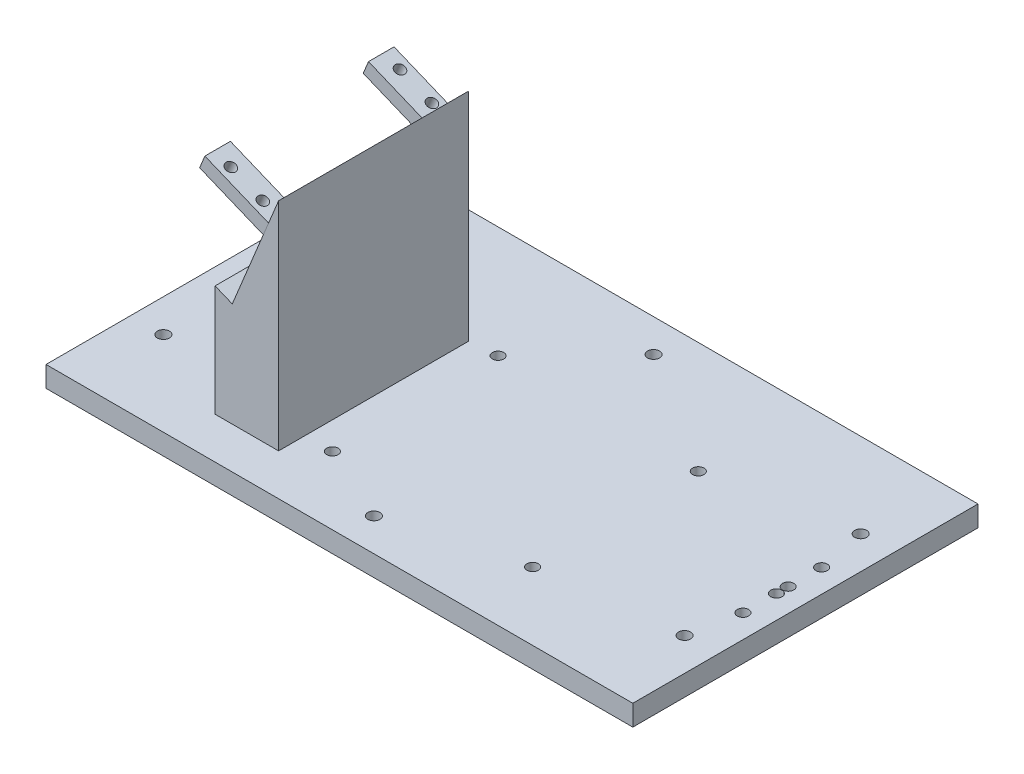
from build123d import *

# Parameters (mm, degrees)
SKETCH1_W                = 170
SKETCH1_H                = 100
BOSS_EXTRUDE1_DEPTH      = 6
BOSS_EXTRUDE2_DEPTH      = 38
BOSS_EXTRUDE2_DEPTH_BACK = 17
SKETCH3_W                = 7.4
SKETCH3_H                = 4
BOSS_EXTRUDE3_DEPTH      = 20
SKETCH5_R                = 1.45
CUT_EXTRUDE1_DEPTH       = 10
SKETCH6_R                = 1.75
CUT_EXTRUDE2_DEPTH       = 20
SKETCH7_R                = 1.65
CUT_EXTRUDE3_DEPTH       = 10
SKETCH9_R                = 1.65
CUT_EXTRUDE6_DEPTH       = 6


with BuildPart() as part:
    # Sketch1 → Boss-Extrude1 (new body)
    with BuildSketch(Plane(origin=(0, 0, 0), x_dir=(1, 0, 0), z_dir=(0, 1, 0))):
        Rectangle(SKETCH1_W, SKETCH1_H)
    extrude(amount=BOSS_EXTRUDE1_DEPTH)

    # Sketch2 → Boss-Extrude2 (add, two sides)
    with BuildSketch(Plane.XY) as boss_extrude2_sk:
        Polygon((-29.617343581, 68.757920077), (-29.617343581, 6), (-48.010328849, 6), (-48.010328849, 38.210127837), (-43.038774216, 36.163017106), align=None)
    extrude(amount=BOSS_EXTRUDE2_DEPTH)
    extrude(boss_extrude2_sk.sketch, amount=-BOSS_EXTRUDE2_DEPTH_BACK)

    # Sketch3 → Boss-Extrude3 (add)
    with BuildSketch(Plane(origin=(-49.531375101, 20.3952721, 0), x_dir=(0, 0, 1), z_dir=(-0.924678098, 0.380749805, 0))):
        with Locations((34.210001, 42.552144992)):
            Rectangle(SKETCH3_W, SKETCH3_H)
        with Locations((-13.189999, 42.552144992)):
            Rectangle(SKETCH3_W, SKETCH3_H)
    extrude(amount=BOSS_EXTRUDE3_DEPTH)

    # Sketch5 → Cut-Extrude1 (cut)
    with BuildSketch(Plane(origin=(15.440221308, 37.49768032, 0), x_dir=(0.924678098, -0.380749805, 0), z_dir=(-0.380749805, -0.924678098, 0))):
        with Locations((-68.566073623, -13.989999)):
            Circle(SKETCH5_R)
        with Locations((-68.566073623, 35.010001)):
            Circle(SKETCH5_R)
        with Locations((-58.566073623, 35.010001)):
            Circle(SKETCH5_R)
        with Locations((-58.566073623, -13.989999)):
            Circle(SKETCH5_R)
    extrude(amount=-CUT_EXTRUDE1_DEPTH, mode=Mode.SUBTRACT)

    # Sketch6 → Cut-Extrude2 (cut)
    with BuildSketch(Plane(origin=(145.967078426, 0, -60.767513946), x_dir=(0, 0, 1), z_dir=(0, -1, 0))):
        with Locations((35.267513946, 221.467078426)):
            Circle(SKETCH6_R)
        with Locations((86.267513946, 221.467078426)):
            Circle(SKETCH6_R)
        with Locations((101.267513946, 145.467078426)):
            Circle(SKETCH6_R)
        with Locations((20.267513946, 145.467078426)):
            Circle(SKETCH6_R)
        with Locations((35.267513946, 70.467078426)):
            Circle(SKETCH6_R)
        with Locations((86.267513946, 70.467078426)):
            Circle(SKETCH6_R)
    extrude(amount=-CUT_EXTRUDE2_DEPTH, mode=Mode.SUBTRACT)

    # Sketch7 → Cut-Extrude3 (cut)
    with BuildSketch(Plane(origin=(0, 6, 0), x_dir=(1, 0, 0), z_dir=(0, 1, 0))):
        with Locations((36.298055455, -30.335990453)):
            Circle(SKETCH7_R)
        with Locations((36.298055455, 17.664009547)):
            Circle(SKETCH7_R)
        with Locations((-21.701944545, 17.664009547)):
            Circle(SKETCH7_R)
        with Locations((-21.701944545, -30.335990453)):
            Circle(SKETCH7_R)
    extrude(amount=-CUT_EXTRUDE3_DEPTH, mode=Mode.SUBTRACT)

    # Sketch9 → Cut-Extrude6 (cut)
    with BuildSketch(Plane(origin=(0, 6, 0), x_dir=(1, 0, 0), z_dir=(0, 1, 0))):
        with Locations((78.25, -11.34)):
            Circle(SKETCH9_R)
        with Locations((78.25, 1.76)):
            Circle(SKETCH9_R)
        with Locations((78.25, 11.44)):
            Circle(SKETCH9_R)
        with Locations((78.25, -1.66)):
            Circle(SKETCH9_R)
    extrude(amount=-CUT_EXTRUDE6_DEPTH, mode=Mode.SUBTRACT)


solid = part.part
